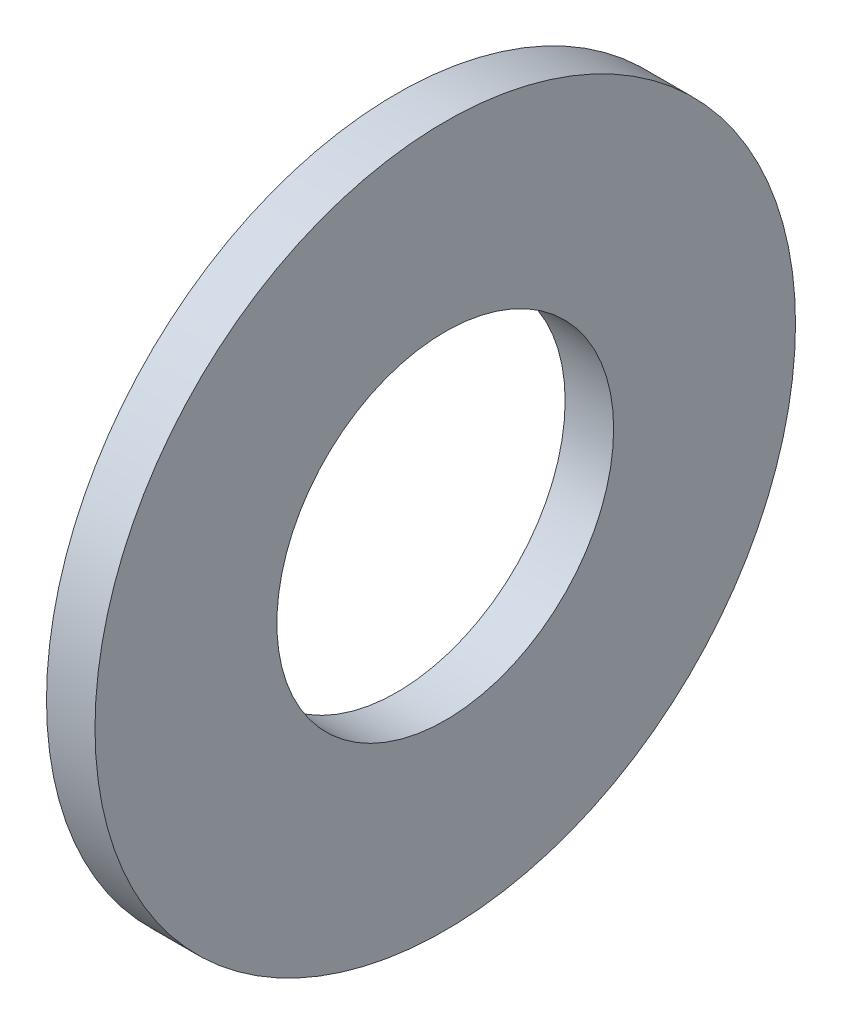
from build123d import *

# Parameters (mm, degrees)
SKETCH1_R           = 26
SKETCH1_R_2         = 12.5
BOSS_EXTRUDE1_DEPTH = 3.6


with BuildPart() as part:
    # Sketch1 → Boss-Extrude1 (new body)
    with BuildSketch(Plane(origin=(0, 0, 0), x_dir=(0, 0, -1), z_dir=(1, 0, 0))):
        Circle(SKETCH1_R)
        Circle(SKETCH1_R_2, mode=Mode.SUBTRACT)
    extrude(amount=BOSS_EXTRUDE1_DEPTH)


solid = part.part
